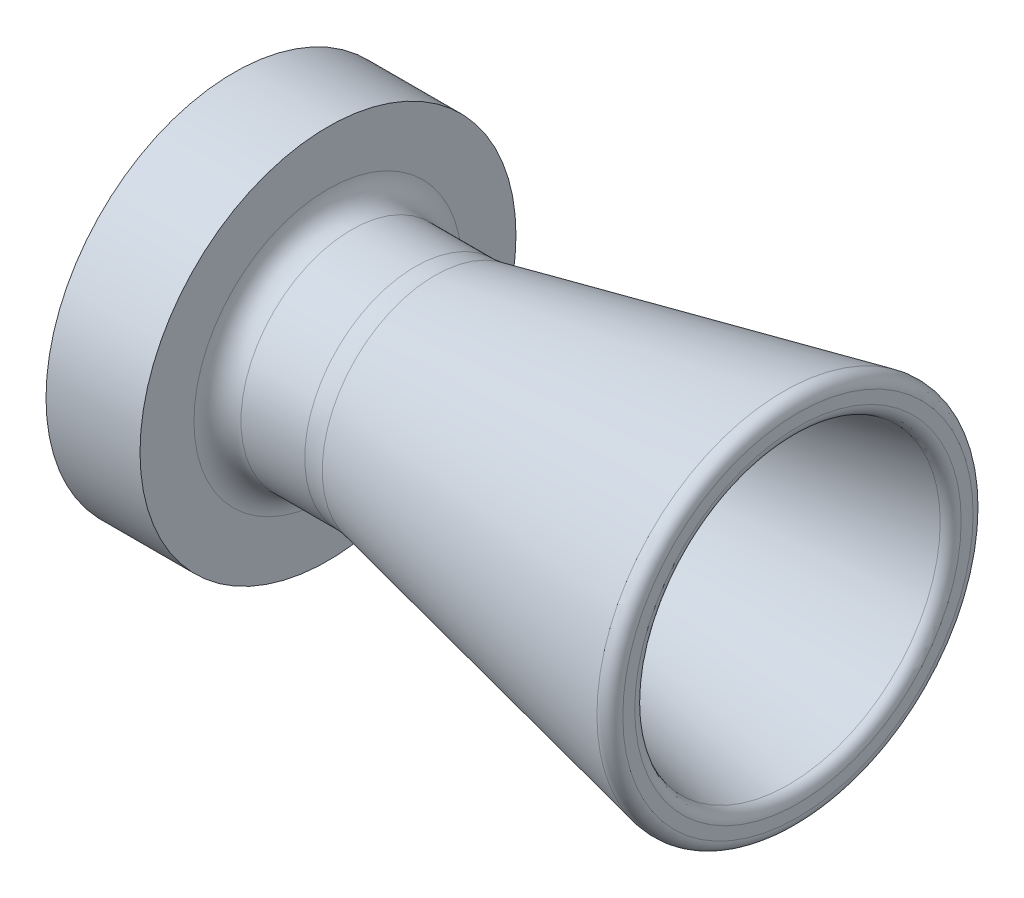
from build123d import *


with BuildPart() as part:
    # Sketch1 → Revolve3 (revolve)
    with BuildSketch(Plane(origin=(0, 0, 0), x_dir=(1, 0, 0), z_dir=(0, 1, 0))):
        with BuildLine():
            Line((-1.932900288, -25.23044077), (-49.062545314, -15.212725471))
            ThreePointArc((-49.062545314, -15.212725471), (-50.375512304, -15.004771929), (-51.703023788, -14.9352))
            Line((-51.703023788, -14.9352), (-60.325, -14.9352))
            ThreePointArc((-60.325, -14.9352), (-62.57006403, -15.86513597), (-63.5, -18.1102))
            Line((-63.5, -18.1102), (-63.5, -25.4))
            Line((-63.5, -25.4), (-76.2, -25.4))
            Line((-76.2, -25.4), (-76.2, -9.525))
            Line((-76.2, -9.525), (-63.5, -9.525))
            Line((-63.5, -9.525), (-63.5, -10.16))
            Line((-63.5, -10.16), (-51.201130044, -10.16))
            ThreePointArc((-51.201130044, -10.16), (-49.87361856, -10.229571929), (-48.56065157, -10.437525471))
            Line((-48.56065157, -10.437525471), (-1.267499712, -20.48999522))
            ThreePointArc((-1.267499712, -20.48999522), (-0.356611032, -21.048188521), (0, -22.055227011))
            Line((0, -22.055227011), (0, -23.66520898))
            ThreePointArc((0, -23.66520898), (-0.59316151, -24.908797947), (-1.932900288, -25.23044077))
        make_face()
    revolve(axis=Axis((88.99, 0, 0), (-1, 0, 0)))


solid = part.part
